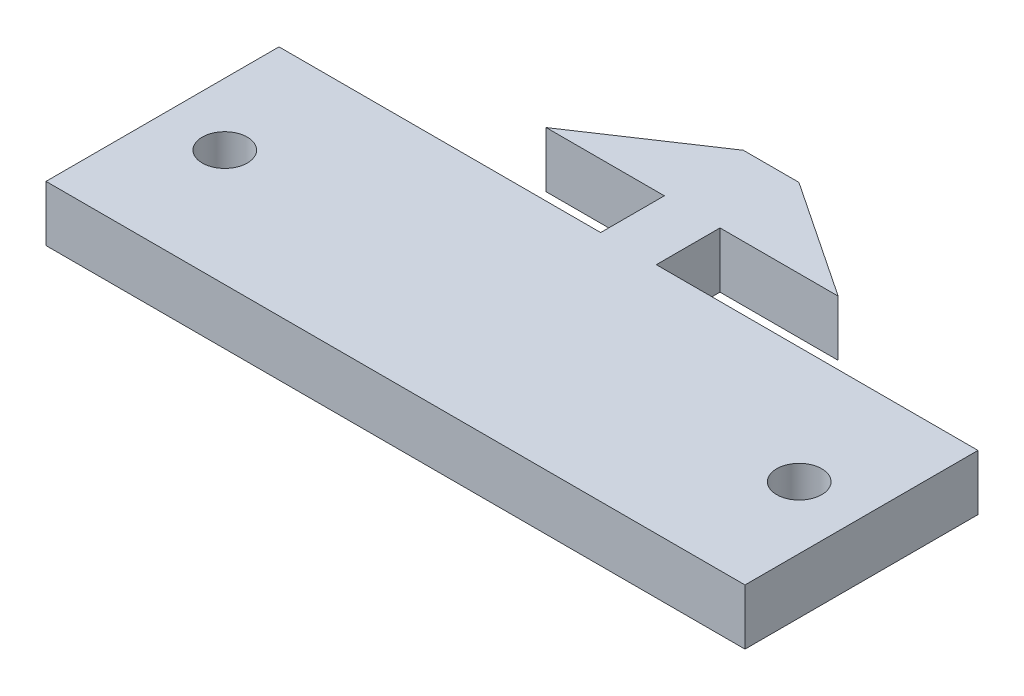
from build123d import *

# Parameters (mm, degrees)
BOSS_EXTRUDE1_DEPTH = 3.5814
SKETCH2_R           = 1.45
CUT_EXTRUDE1_DEPTH  = 4.5814


with BuildPart() as part:
    # Sketch1 → Boss-Extrude1 (new body)
    with BuildSketch(Plane(origin=(0, 0, 0), x_dir=(1, 0, 0), z_dir=(0, 1, 0))):
        Polygon((-22.5, -17.05), (22.5, -17.05), (22.5, -2.05), (1.7907, -2.05), (1.7907, 2.05), (9.398, 2.05), (1.7907, 7.13), (-1.7907, 7.13), (-9.398, 2.05), (-1.7907, 2.05), (-1.7907, -2.05), (-22.5, -2.05), align=None)
    extrude(amount=BOSS_EXTRUDE1_DEPTH)

    # Sketch2 → Cut-Extrude1 (cut, through all)
    with BuildSketch(Plane(origin=(0, 3.5814, 0), x_dir=(1, 0, 0), z_dir=(0, 1, 0))):
        with Locations((-18.49, -9.55)):
            Circle(SKETCH2_R)
        with Locations((18.49, -9.55)):
            Circle(SKETCH2_R)
    extrude(amount=-CUT_EXTRUDE1_DEPTH, mode=Mode.SUBTRACT)


solid = part.part
